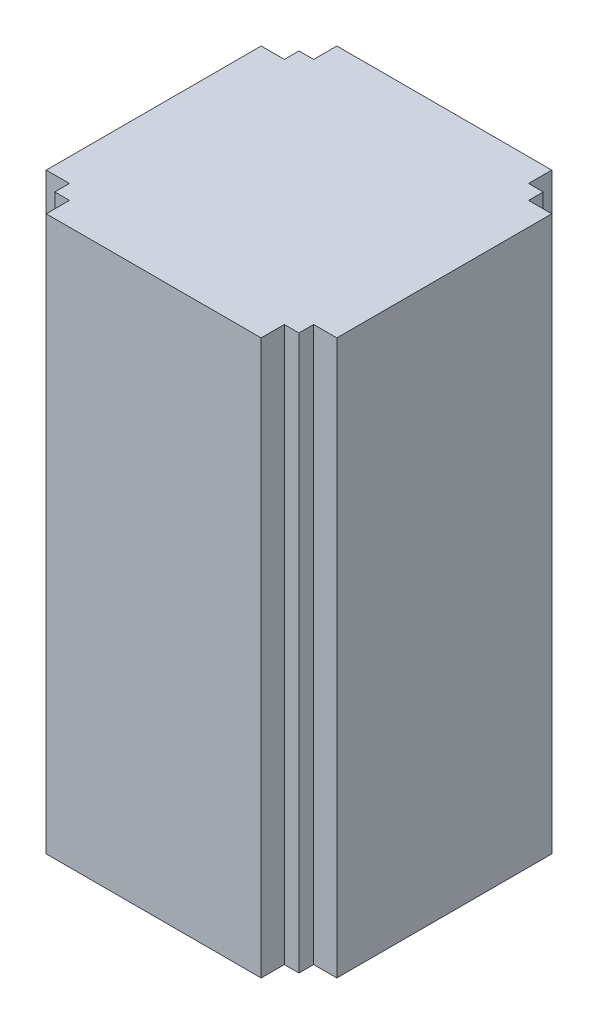
from build123d import *

# Parameters (mm, degrees)
BOSS_EXTRUDE1_DEPTH = 227


with BuildPart() as part:
    # Sketch1 → Boss-Extrude1 (new body)
    with BuildSketch(Plane(origin=(0, 0, 0), x_dir=(1, 0, 0), z_dir=(0, 1, 0))):
        Polygon((-44, 50), (-44, 59.5), (44, 59.5), (44, 50), (50, 50), (50, 44), (59.5, 44), (59.5, -44), (50, -44), (50, -50), (44, -50), (44, -59.5), (-44, -59.5), (-44, -50), (-50, -50), (-50, -44), (-59.5, -44), (-59.5, 44), (-50, 44), (-50, 50), align=None)
    extrude(amount=BOSS_EXTRUDE1_DEPTH)


solid = part.part
